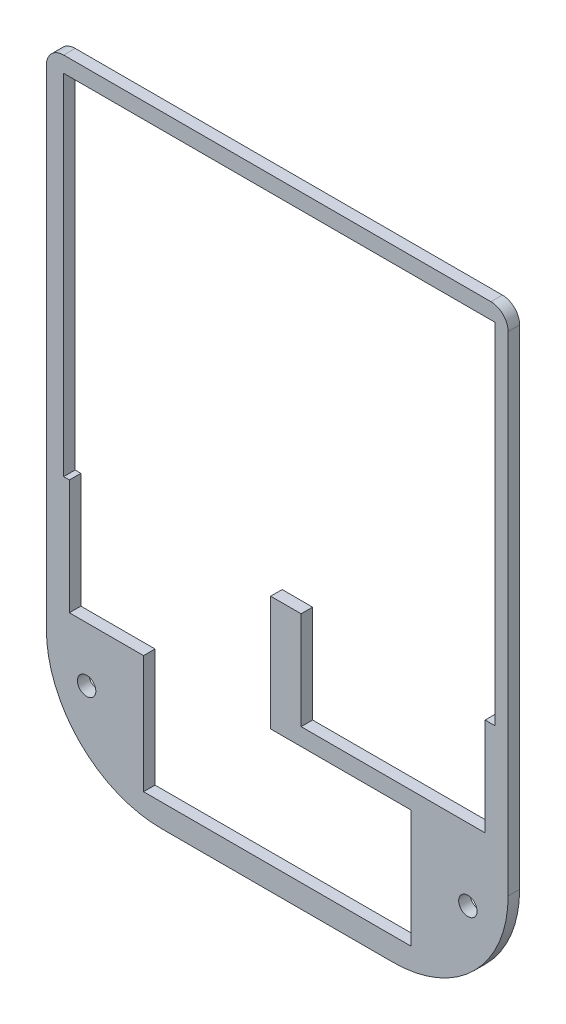
from build123d import *

# Parameters (mm, degrees)
SKETCH1_W                      = 80.3
SKETCH1_H                      = 66
BOSS_EXTRUDE1_DEPTH            = 2
F_3_2_3_2_DIAMETER_HOLE1_D     = 3.2
FILLET1_R                      = 3
SKETCH4_W                      = 80.3
SKETCH4_H                      = 2
BOSS_EXTRUDE2_DEPTH            = 42
FILLET2_R                      = 20
F_3_2_3_2_DIAMETER_HOLE2_D     = 3.2
F_3_2_3_2_DIAMETER_HOLE2_DEPTH = 60
F_3_2_3_2_DIAMETER_HOLE2_TIP   = 0.96137699
SKETCH7_W                      = 75
SKETCH7_H                      = 60.5
CUT_EXTRUDE1_DEPTH             = 3
SKETCH10_W                     = 35
SKETCH10_H                     = 20
SKETCH10_W_2                   = 32
SKETCH10_H_2                   = 17
CUT_EXTRUDE3_DEPTH             = 3
SKETCH11_W                     = 75
SKETCH11_H                     = 0.25
CUT_EXTRUDE4_DEPTH             = 3


with BuildPart() as part:
    # Sketch1 → Boss-Extrude1 (new body)
    with BuildSketch(Plane.XY):
        with Locations((40.15, 33)):
            Rectangle(SKETCH1_W, SKETCH1_H)
    extrude(amount=BOSS_EXTRUDE1_DEPTH)

    # Ø3.2 (3.2) Diameter Hole1 (through all)
    with Locations(Plane.XY.offset(2)):
        with Locations((7, 59), (73.3, 59), (73.3, 7), (7, 7)):
            Hole(F_3_2_3_2_DIAMETER_HOLE1_D / 2)

    # Fillet1
    fillet1_edges = [part.edges().sort_by_distance(p)[0] for p in [
        (0, 66, 1),
        (80.3, 66, 1),
    ]]
    fillet(fillet1_edges, radius=FILLET1_R)

    # Sketch4 → Boss-Extrude2 (add)
    with BuildSketch(Plane.XZ):
        with Locations((40.15, 1)):
            Rectangle(SKETCH4_W, SKETCH4_H)
    extrude(amount=BOSS_EXTRUDE2_DEPTH)

    # Fillet2
    fillet2_edges = [part.edges().sort_by_distance(p)[0] for p in [
        (0, -42, 1),
        (80.3, -42, 1),
    ]]
    fillet(fillet2_edges, radius=FILLET2_R)

    # Ø3.2 (3.2) Diameter Hole2
    with Locations(Plane.XY.offset(2)):
        with Locations((7, -27), (73.3, -27)):
            Hole(F_3_2_3_2_DIAMETER_HOLE2_D / 2, depth=F_3_2_3_2_DIAMETER_HOLE2_DEPTH)
            with Locations((0, 0, -(F_3_2_3_2_DIAMETER_HOLE2_DEPTH + F_3_2_3_2_DIAMETER_HOLE2_TIP / 2))):  # 118° drill point
                Cone(0, F_3_2_3_2_DIAMETER_HOLE2_D / 2, F_3_2_3_2_DIAMETER_HOLE2_TIP, mode=Mode.SUBTRACT)

    # Sketch7 → Cut-Extrude1 (cut, through all)
    with BuildSketch(Plane.XY.offset(2)):
        with Locations((40.5, 33)):
            Rectangle(SKETCH7_W, SKETCH7_H)
    extrude(amount=-CUT_EXTRUDE1_DEPTH, mode=Mode.SUBTRACT)

    # Sketch10 → Cut-Extrude3 (cut, through all)
    with BuildSketch(Plane.XY.offset(2)):
        with Locations((21.5, -7.5)):
            Rectangle(SKETCH10_W, SKETCH10_H)
        Polygon((63.4, -17.5), (39, -17.5), (16.9, -17.5), (16.9, -38), (63.4, -38), align=None)
        with Locations((60.3, -6)):
            Rectangle(SKETCH10_W_2, SKETCH10_H_2)
    extrude(amount=-CUT_EXTRUDE3_DEPTH, mode=Mode.SUBTRACT)

    # Sketch11 → Cut-Extrude4 (cut, through all)
    with BuildSketch(Plane.XY.offset(2)):
        with Locations((40.5, 2.625)):
            Rectangle(SKETCH11_W, SKETCH11_H)
    extrude(amount=-CUT_EXTRUDE4_DEPTH, mode=Mode.SUBTRACT)


solid = part.part
